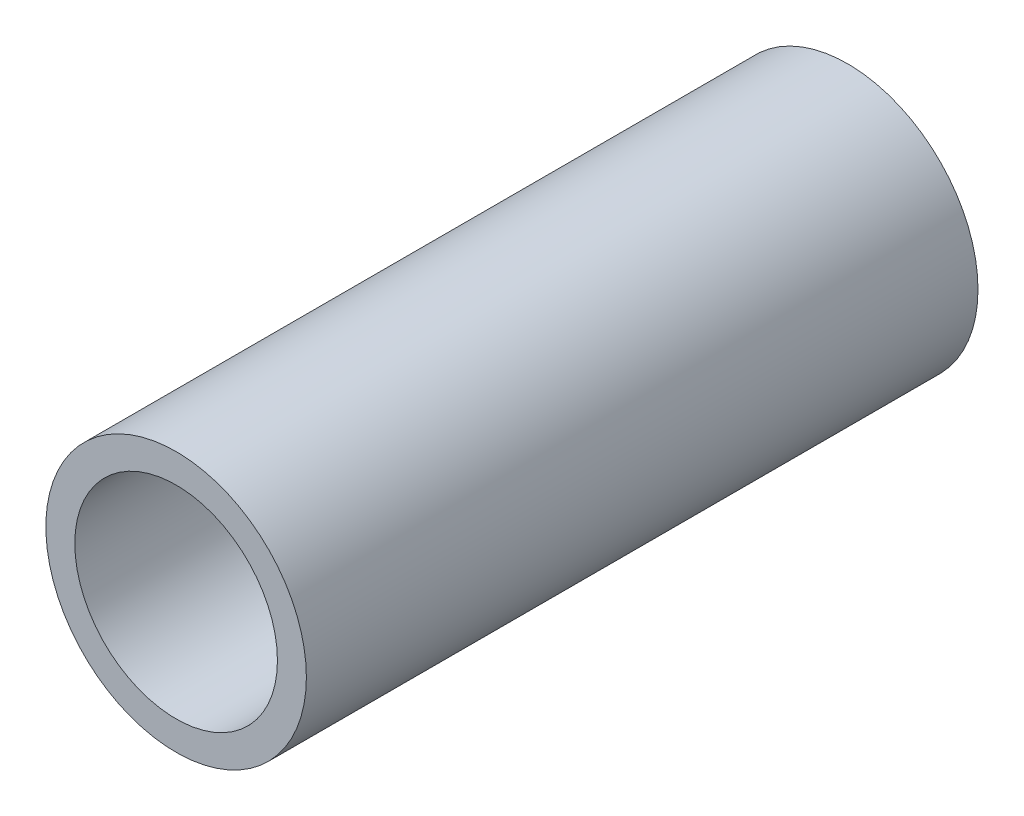
from build123d import *

# Parameters (mm, degrees)
ESQUISSE1_R      = 5.625
ESQUISSE1_R_2    = 4.375
EXTRUSION1_DEPTH = 29


with BuildPart() as part:
    # Esquisse1 → Extrusion1 (new body)
    with BuildSketch(Plane.XY):
        Circle(ESQUISSE1_R)
        Circle(ESQUISSE1_R_2, mode=Mode.SUBTRACT)
    extrude(amount=EXTRUSION1_DEPTH)


solid = part.part
